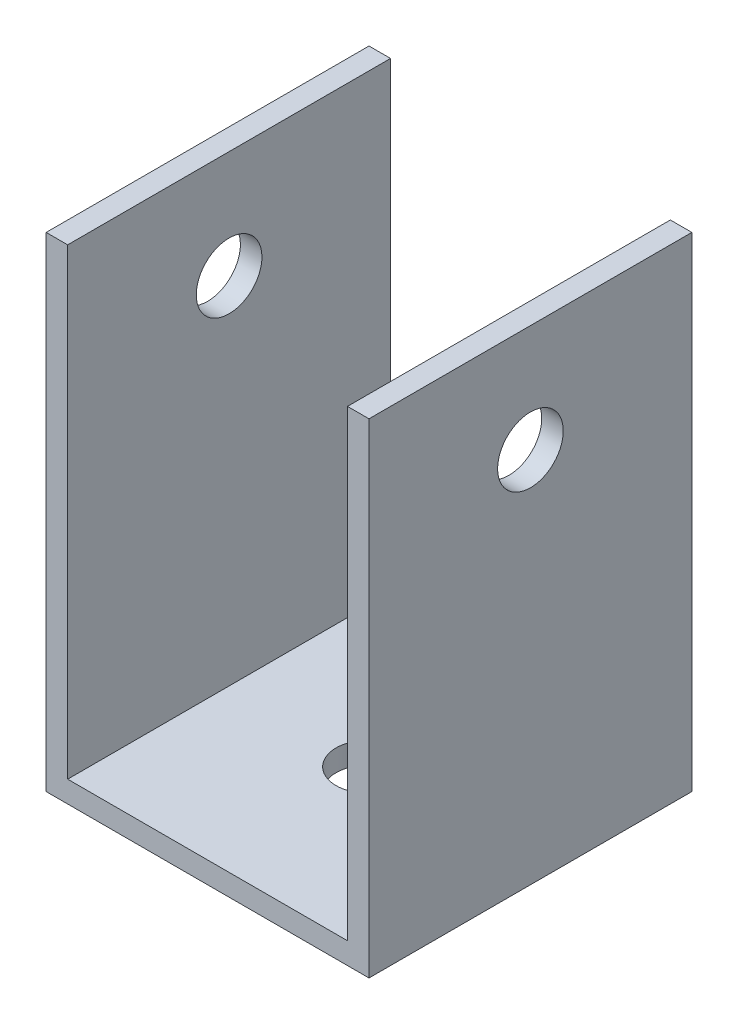
from build123d import *

# Parameters (mm, degrees)
EXTRUDE_1_DEPTH     = 30
SKETCH_2_R          = 3.05
CUT_EXTRUDE_1_DEPTH = 30
SKETCH_3_R          = 3.05
CUT_EXTRUDE_2_DEPTH = 38


with BuildPart() as part:
    # 草图1 → 凸台-拉伸1 (new body)
    with BuildSketch(Plane.XY):
        Polygon((-15, 37.701761355), (-13, 37.701761355), (-13, -5.298238645), (13, -5.298238645), (13, 37.701761355), (15, 37.701761355), (15, -7.298238645), (-15, -7.298238645), align=None)
    extrude(amount=EXTRUDE_1_DEPTH)

    # 草图2 → 切除-拉伸1 (cut)
    with BuildSketch(Plane(origin=(0, 0, 0), x_dir=(1, 0, 0), z_dir=(0, 1, 0))):
        with Locations((0, -15)):
            Circle(SKETCH_2_R)
    extrude(amount=-CUT_EXTRUDE_1_DEPTH, mode=Mode.SUBTRACT)

    # 草图3 → 切除-拉伸2 (cut)
    with BuildSketch(Plane.ZY.offset(15)):
        with Locations((15, 27.701761355)):
            Circle(SKETCH_3_R)
    extrude(amount=-CUT_EXTRUDE_2_DEPTH, mode=Mode.SUBTRACT)


solid = part.part
